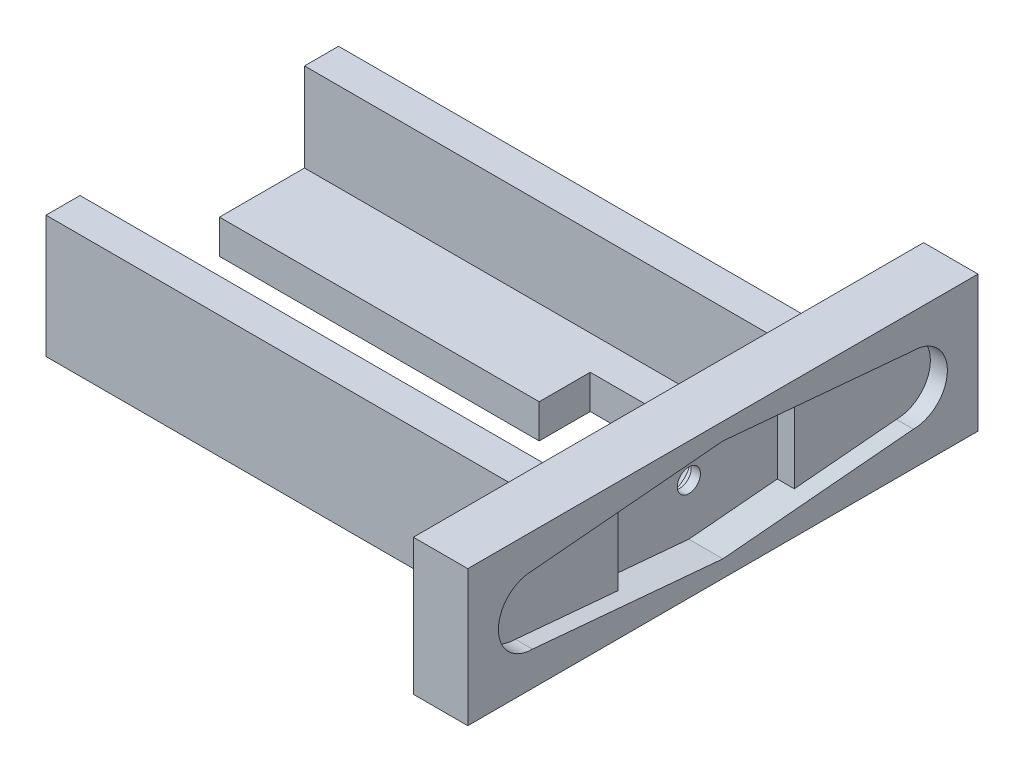
from build123d import *

# Parameters (mm, degrees)
SKETCH_1_W                   = 10
SKETCH_1_H                   = 75
EXTRUDE_2_DEPTH              = 20
SKETCH_4_W                   = 75
SKETCH_4_H                   = 20
CUT_EXTRUDE_3_DEPTH          = 2
CUT_EXTRUDE_4_DEPTH          = 2.5
CUT_EXTRUDE_5_DEPTH          = 5
SKETCH_10_W                  = 33
SKETCH_10_H                  = 5
EXTRUDE_3_DEPTH              = 70
SKETCH_11_W                  = 5
SKETCH_11_H                  = 18
EXTRUDE_4_DEPTH              = 70
SKETCH_12_W                  = 5
SKETCH_12_H                  = 18
EXTRUDE_5_DEPTH              = 70
SKETCH_13_W                  = 60
SKETCH_13_H                  = 8
CUT_EXTRUDE_6_DEPTH          = 20
SKETCH_14_W                  = 10
SKETCH_14_H                  = 21.760680977
CUT_EXTRUDE_7_DEPTH          = 20
HOLE_WIZARD_M3_1_D           = 3.4
HOLE_WIZARD_M3_1_DEPTH       = 20
HOLE_WIZARD_M3_1_CBORE_D     = 6.7
HOLE_WIZARD_M3_1_CBORE_DEPTH = 1.65
HOLE_WIZARD_M3_1_TIP         = 1.021463052


with BuildPart() as part:
    # 草图1 → 凸台-拉伸2 (new body)
    with BuildSketch(Plane(origin=(0, 0, 0), x_dir=(1, 0, 0), z_dir=(0, 1, 0))):
        with Locations((5, 37.5)):
            Rectangle(SKETCH_1_W, SKETCH_1_H)
    extrude(amount=EXTRUDE_2_DEPTH)

    # 草图4 → 切除-拉伸3 (cut)
    with BuildSketch(Plane(origin=(10, 0, 0), x_dir=(0, 0, -1), z_dir=(1, 0, 0))):
        with Locations((37.5, 10)):
            Rectangle(SKETCH_4_W, SKETCH_4_H)
    extrude(amount=-CUT_EXTRUDE_3_DEPTH, mode=Mode.SUBTRACT)

    # 草图5 → 切除-拉伸4 (cut)
    with BuildSketch(Plane(origin=(8, 0, 0), x_dir=(0, 0, -1), z_dir=(1, 0, 0))):
        with BuildLine():
            Line((65.5, 15), (38.828693451, 17.381366656))
            ThreePointArc((38.828693451, 17.381366656), (43.253920441, 14.810654795), (45, 10))
            ThreePointArc((45, 10), (43.253920441, 5.189345205), (38.828693451, 2.618633344))
            Line((38.828693451, 2.618633344), (65.5, 5))
            ThreePointArc((65.5, 5), (70.5, 10), (65.5, 15))
        make_face()
        with BuildLine():
            Line((37.5, 17.5), (36.171306549, 17.381366656))
            ThreePointArc((36.171306549, 17.381366656), (30, 10), (36.171306549, 2.618633344))
            Line((36.171306549, 2.618633344), (37.5, 2.5))
            Line((37.5, 2.5), (38.828693451, 2.618633344))
            ThreePointArc((38.828693451, 2.618633344), (43.253920441, 5.189345205), (45, 10))
            ThreePointArc((45, 10), (43.253920441, 14.810654795), (38.828693451, 17.381366656))
            Line((38.828693451, 17.381366656), (37.5, 17.5))
        make_face()
        with BuildLine():
            Line((36.171306549, 17.381366656), (9.5, 15))
            ThreePointArc((9.5, 15), (4.5, 10), (9.5, 5))
            Line((9.5, 5), (36.171306549, 2.618633344))
            ThreePointArc((36.171306549, 2.618633344), (30, 10), (36.171306549, 17.381366656))
        make_face()
    extrude(amount=-CUT_EXTRUDE_4_DEPTH, mode=Mode.SUBTRACT)

    # 草图6 → 切除-拉伸5 (cut)
    with BuildSketch(Plane(origin=(8, 0, 0), x_dir=(0, 0, -1), z_dir=(1, 0, 0))):
        Polygon((37.5, 17.5), (24.551509831, 16.343884806), (24.551509831, 3.656115194), (37.5, 2.5), (50.5, 3.660714286), (50.5, 16.339285714), align=None)
    extrude(amount=-CUT_EXTRUDE_5_DEPTH, mode=Mode.SUBTRACT)

    # 草图10 → 凸台-拉伸3 (add)
    with BuildSketch(Plane.ZY):
        with Locations((-37.5, 2.5)):
            Rectangle(SKETCH_10_W, SKETCH_10_H)
    extrude(amount=EXTRUDE_3_DEPTH)

    # 草图11 → 凸台-拉伸4 (add)
    with BuildSketch(Plane.ZY):
        with Locations((-18.5, 9)):
            Rectangle(SKETCH_11_W, SKETCH_11_H)
    extrude(amount=EXTRUDE_4_DEPTH)

    # 草图12 → 凸台-拉伸5 (add)
    with BuildSketch(Plane.ZY):
        with Locations((-56.5, 9)):
            Rectangle(SKETCH_12_W, SKETCH_12_H)
    extrude(amount=EXTRUDE_5_DEPTH)

    # 草图13 → 切除-拉伸6 (cut)
    with BuildSketch(Plane(origin=(0, 5, 0), x_dir=(1, 0, 0), z_dir=(0, 1, 0))):
        with Locations((-40, 37.5)):
            Rectangle(SKETCH_13_W, SKETCH_13_H)
    extrude(amount=-CUT_EXTRUDE_6_DEPTH, mode=Mode.SUBTRACT)

    # 草图14 → 切除-拉伸7 (cut)
    with BuildSketch(Plane(origin=(0, 5, 0), x_dir=(1, 0, 0), z_dir=(0, 1, 0))):
        with Locations((-18, 38.119659512)):
            Rectangle(SKETCH_14_W, SKETCH_14_H)
    extrude(amount=-CUT_EXTRUDE_7_DEPTH, mode=Mode.SUBTRACT)

    # M3 凹圆头螺钉的柱形沉头孔1
    with Locations(Plane(origin=(0, 10, -37.5), x_dir=(0, 0, -1), z_dir=(-1, 0, 0))):
        with Locations((0, 0)):
            CounterBoreHole(HOLE_WIZARD_M3_1_D / 2, HOLE_WIZARD_M3_1_CBORE_D / 2, HOLE_WIZARD_M3_1_CBORE_DEPTH, depth=HOLE_WIZARD_M3_1_DEPTH)
            with Locations((0, 0, -(HOLE_WIZARD_M3_1_DEPTH + HOLE_WIZARD_M3_1_TIP / 2))):  # 118° drill point
                Cone(0, HOLE_WIZARD_M3_1_D / 2, HOLE_WIZARD_M3_1_TIP, mode=Mode.SUBTRACT)


solid = part.part
